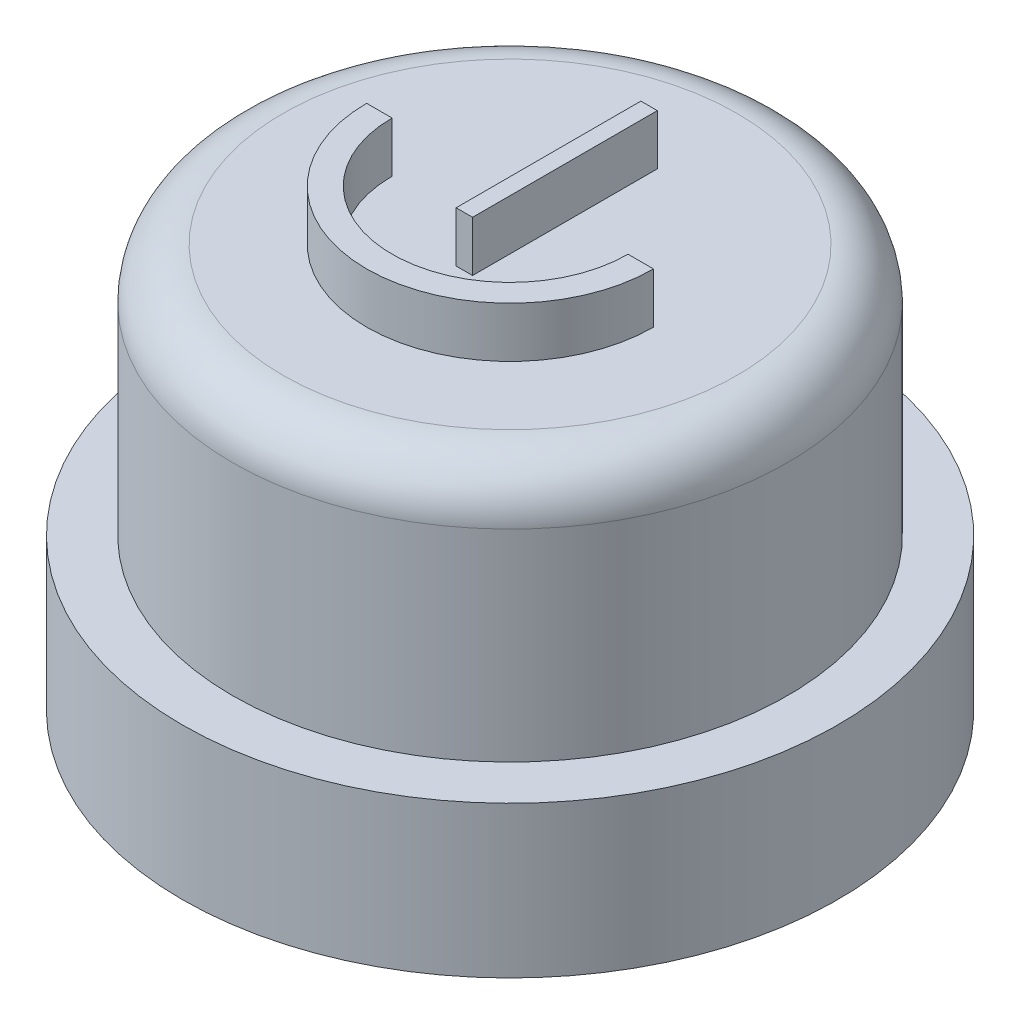
from build123d import *

# Parameters (mm, degrees)
SKETCH_1_R      = 6.5
EXTRUDE_2_DEPTH = 3
SKETCH_3_R      = 5.5
EXTRUDE_3_DEPTH = 5
FILLET_1_R      = 1
SKETCH_4_W      = 0.326388432
SKETCH_4_H      = 3.66280352
EXTRUDE_4_DEPTH = 1


with BuildPart() as part:
    # 草图1 → 凸台-拉伸2 (new body)
    with BuildSketch(Plane(origin=(0, 0, 0), x_dir=(1, 0, 0), z_dir=(0, 1, 0))):
        Circle(SKETCH_1_R)
    extrude(amount=EXTRUDE_2_DEPTH)

    # 草图3 → 凸台-拉伸3 (add)
    with BuildSketch(Plane(origin=(0, 3, 0), x_dir=(1, 0, 0), z_dir=(0, 1, 0))):
        Circle(SKETCH_3_R)
    extrude(amount=EXTRUDE_3_DEPTH)

    # 圆角1
    fillet_1_edges = [part.edges().sort_by_distance(p)[0] for p in [
        (-5.5, 8, 0),
    ]]
    fillet(fillet_1_edges, radius=FILLET_1_R)

    # 草图4 → 凸台-拉伸4 (add)
    with BuildSketch(Plane(origin=(0, 8, 0), x_dir=(1, 0, 0), z_dir=(0, 1, 0))):
        with BuildLine():
            Line((-2.843597496, 0), (-2.339117099, 0))
            ThreePointArc((-2.339117099, 0), (0, -2.339117099), (2.339117099, 0))
            Line((2.339117099, 0), (2.843597496, 0))
            ThreePointArc((2.843597496, 0), (0, -2.843597496), (-2.843597496, 0))
        make_face()
        with Locations((0, 0.924767225)):
            Rectangle(SKETCH_4_W, SKETCH_4_H)
    extrude(amount=EXTRUDE_4_DEPTH)


solid = part.part
